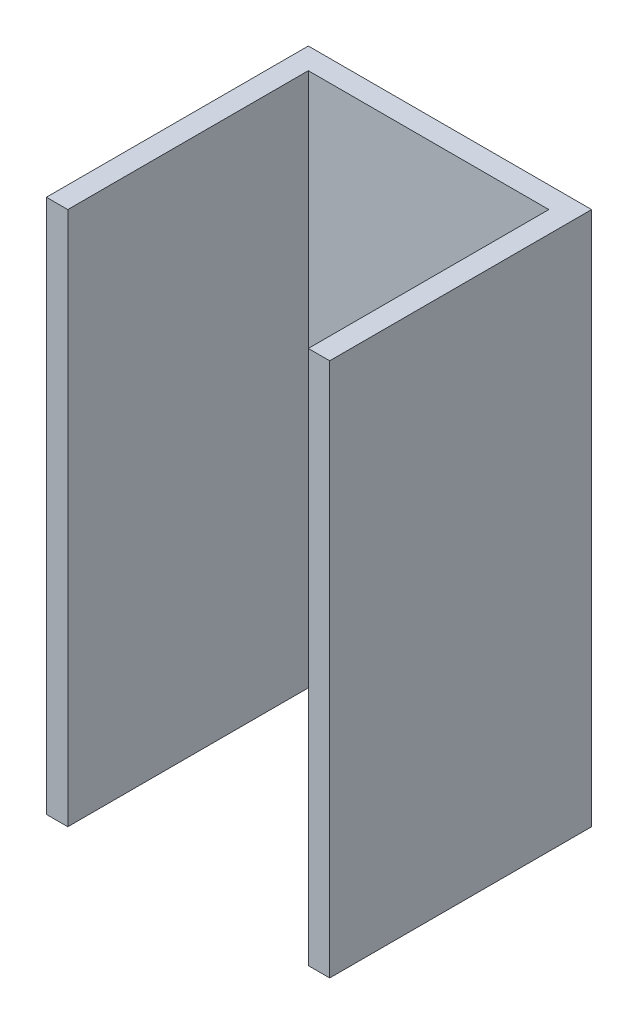
from build123d import *

# Parameters (mm, degrees)
BOSS_EXTRUDE1_DEPTH = 50


with BuildPart() as part:
    # Sketch1 → Boss-Extrude1 (new body)
    with BuildSketch(Plane(origin=(0, 0, 0), x_dir=(1, 0, 0), z_dir=(0, 1, 0))):
        Polygon((-11.25, 0), (11.25, 0), (11.25, -22.5), (13.25, -22.5), (13.25, 2), (-13.25, 2), (-13.25, -22.5), (-11.25, -22.5), align=None)
    extrude(amount=BOSS_EXTRUDE1_DEPTH)


solid = part.part
